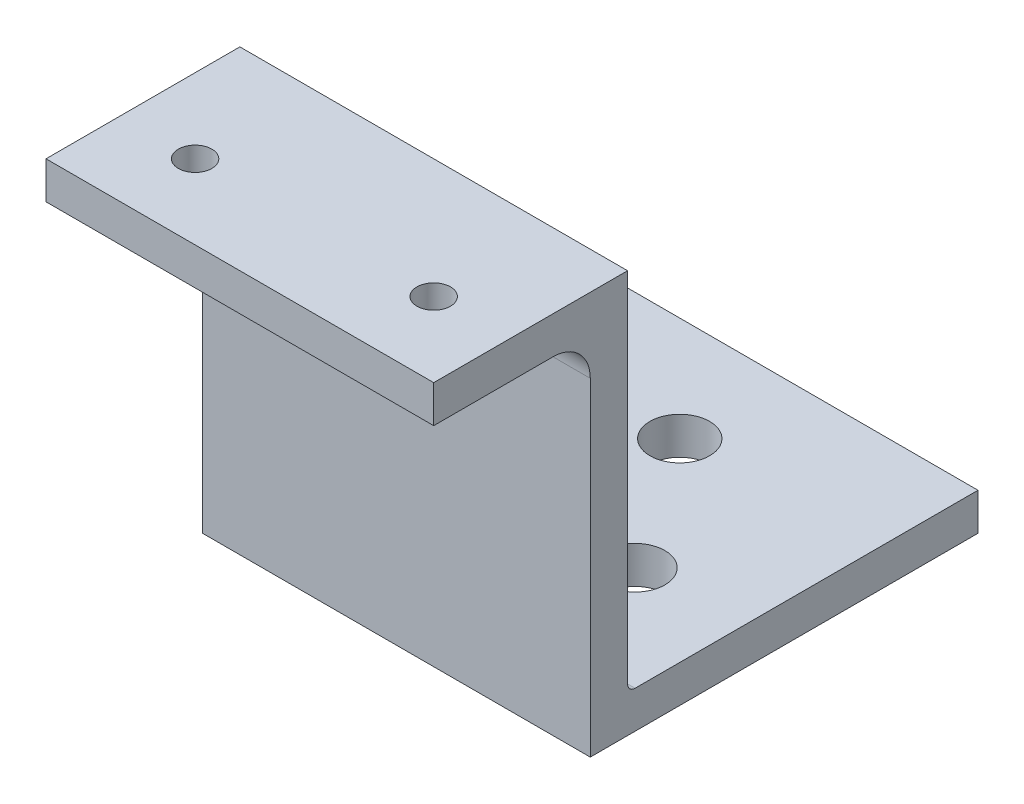
from build123d import *

# Parameters (mm, degrees)
SKETCH1_W           = 52
SKETCH1_H           = 52
SKETCH1_W_2         = 42
SKETCH1_H_2         = 42
BOSS_EXTRUDE1_DEPTH = 5
SKETCH2_W           = 52
SKETCH2_H           = 52
BOSS_EXTRUDE2_DEPTH = 5
SKETCH3_W           = 52
SKETCH3_H           = 5
BOSS_EXTRUDE3_DEPTH = 44
SKETCH4_W           = 52
SKETCH4_H           = 26
BOSS_EXTRUDE4_DEPTH = 5
SKETCH5_R           = 2.25
CUT_EXTRUDE1_DEPTH  = 60
FILLET1_R           = 5
FILLET2_R           = 1
SKETCH7_R           = 4
CUT_EXTRUDE2_DEPTH  = 55
SKETCH8_W           = 52
SKETCH8_H           = 52
SKETCH8_W_2         = 42
SKETCH8_H_2         = 42
CUT_EXTRUDE3_DEPTH  = 5


with BuildPart() as part:
    # Sketch1 → Boss-Extrude1 (new body)
    with BuildSketch(Plane(origin=(0, 0, 0), x_dir=(1, 0, 0), z_dir=(0, 1, 0))):
        with Locations((20, 20)):
            Rectangle(SKETCH1_W, SKETCH1_H)
        with Locations((20, 20)):
            Rectangle(SKETCH1_W_2, SKETCH1_H_2, mode=Mode.SUBTRACT)
    extrude(amount=BOSS_EXTRUDE1_DEPTH)

    # Sketch2 → Boss-Extrude2 (add)
    with BuildSketch(Plane(origin=(0, 5, 0), x_dir=(1, 0, 0), z_dir=(0, 1, 0))):
        with Locations((20, 20)):
            Rectangle(SKETCH2_W, SKETCH2_H)
    extrude(amount=BOSS_EXTRUDE2_DEPTH)

    # Sketch3 → Boss-Extrude3 (add)
    with BuildSketch(Plane(origin=(0, 10, 0), x_dir=(1, 0, 0), z_dir=(0, 1, 0))):
        with Locations((20, -3.5)):
            Rectangle(SKETCH3_W, SKETCH3_H)
    extrude(amount=BOSS_EXTRUDE3_DEPTH)

    # Sketch4 → Boss-Extrude4 (add)
    with BuildSketch(Plane(origin=(0, 54, 0), x_dir=(1, 0, 0), z_dir=(0, 1, 0))):
        with Locations((20, -14)):
            Rectangle(SKETCH4_W, SKETCH4_H)
    extrude(amount=BOSS_EXTRUDE4_DEPTH)

    # Sketch5 → Cut-Extrude1 (cut, through all)
    with BuildSketch(Plane(origin=(0, 59, 0), x_dir=(1, 0, 0), z_dir=(0, 1, 0))):
        with Locations((36, -17)):
            Circle(SKETCH5_R)
        with Locations((4, -17)):
            Circle(SKETCH5_R)
    extrude(amount=-CUT_EXTRUDE1_DEPTH, mode=Mode.SUBTRACT)

    # Fillet1
    fillet1_edges = [part.edges().sort_by_distance(p)[0] for p in [
        (20, 54, 6),
    ]]
    fillet(fillet1_edges, radius=FILLET1_R)

    # Fillet2
    fillet2_edges = [part.edges().sort_by_distance(p)[0] for p in [
        (20, 10, 1),
    ]]
    fillet(fillet2_edges, radius=FILLET2_R)

    # Sketch7 → Cut-Extrude2 (cut, through all)
    with BuildSketch(Plane.XZ.offset(-5)):
        with Locations((20, -32)):
            Circle(SKETCH7_R)
        with Locations((32, -14)):
            Circle(SKETCH7_R)
        with Locations((8, -14)):
            Circle(SKETCH7_R)
    extrude(amount=-CUT_EXTRUDE2_DEPTH, mode=Mode.SUBTRACT)

    # Sketch8 → Cut-Extrude3 (cut)
    with BuildSketch(Plane.XZ):
        with Locations((20, -20)):
            Rectangle(SKETCH8_W, SKETCH8_H)
        with Locations((20, -20)):
            Rectangle(SKETCH8_W_2, SKETCH8_H_2, mode=Mode.SUBTRACT)
    extrude(amount=-CUT_EXTRUDE3_DEPTH, mode=Mode.SUBTRACT)


solid = part.part
